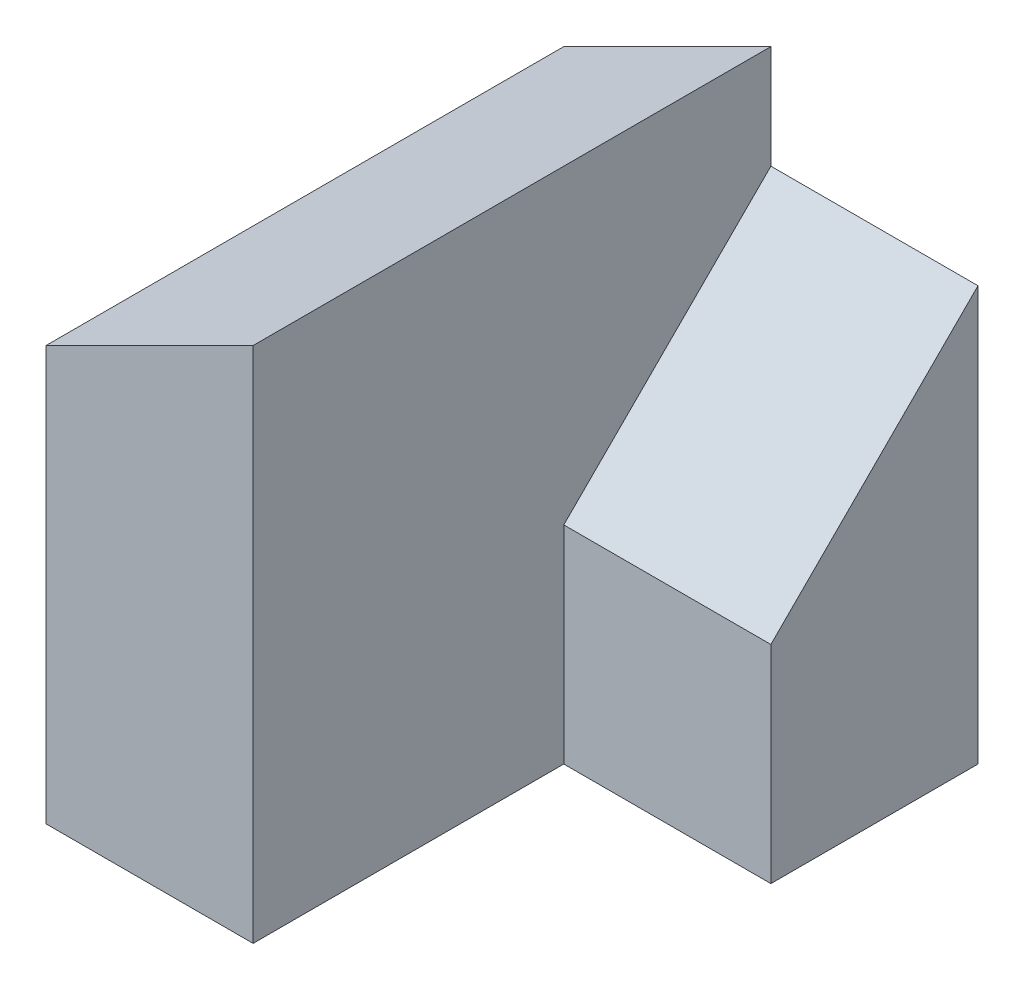
from build123d import *

# Parameters (mm, degrees)
SKETCH1_W           = 10
SKETCH1_H           = 25
BOSS_EXTRUDE1_DEPTH = 25
SKETCH2_W           = 10
SKETCH2_H           = 20
BOSS_EXTRUDE2_DEPTH = 10
CUT_EXTRUDE1_DEPTH  = 40
CUT_EXTRUDE2_DEPTH  = 10
SKETCH5_W           = 15
SKETCH5_H           = 10
BOSS_EXTRUDE3_DEPTH = 10


with BuildPart() as part:
    # Sketch1 → Boss-Extrude1 (new body)
    with BuildSketch(Plane.XY):
        with Locations((5, 12.5)):
            Rectangle(SKETCH1_W, SKETCH1_H)
    extrude(amount=BOSS_EXTRUDE1_DEPTH)

    # Sketch2 → Boss-Extrude2 (add)
    with BuildSketch(Plane(origin=(10, 0, 0), x_dir=(0, 0, -1), z_dir=(1, 0, 0))):
        with Locations((-5, 10)):
            Rectangle(SKETCH2_W, SKETCH2_H)
    extrude(amount=BOSS_EXTRUDE2_DEPTH)

    # Sketch3 → Cut-Extrude1 (cut)
    with BuildSketch(Plane.XY.offset(25)):
        Polygon((10, 25), (0, 20), (0, 25), align=None)
    extrude(amount=-CUT_EXTRUDE1_DEPTH, mode=Mode.SUBTRACT)

    # Sketch4 → Cut-Extrude2 (cut)
    with BuildSketch(Plane(origin=(20, 0, 0), x_dir=(0, 0, -1), z_dir=(1, 0, 0))):
        Polygon((-10, 10), (0, 20), (-10, 20), align=None)
    extrude(amount=-CUT_EXTRUDE2_DEPTH, mode=Mode.SUBTRACT)

    # Sketch5 → Boss-Extrude3 (add)
    with BuildSketch(Plane.ZY):
        with Locations((7.5, 5)):
            Rectangle(SKETCH5_W, SKETCH5_H)
    extrude(amount=BOSS_EXTRUDE3_DEPTH)


solid = part.part
